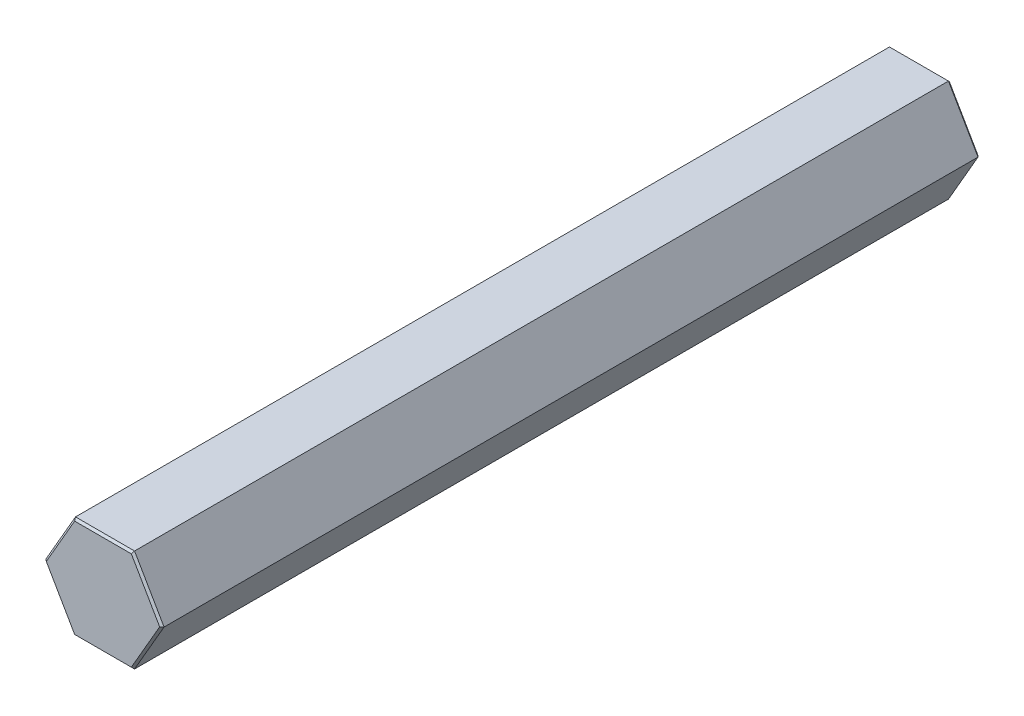
from build123d import *

# Parameters (mm, degrees)
BOSS_EXTRUDE1_DEPTH = 101.6
CHAMFER1_SIZE       = 0.254


with BuildPart() as part:
    # Sketch1 → Boss-Extrude1 (new body)
    with BuildSketch(Plane(origin=(0, 0, 0), x_dir=(-1, 0, 0), z_dir=(0, 0, -1))):
        Polygon((3.666174209, 6.35), (-3.666174209, 6.35), (-7.332348419, 0), (-3.666174209, -6.35), (3.666174209, -6.35), (7.332348419, 0), align=None)
    extrude(amount=-BOSS_EXTRUDE1_DEPTH)

    # Chamfer1
    chamfer1_edges = [part.edges().sort_by_distance(p)[0] for p in [
        (5.499261314, 3.175, 101.6),
        (5.499261314, -3.175, 101.6),
        (0, -6.35, 101.6),
        (-5.499261314, -3.175, 101.6),
        (-5.499261314, 3.175, 101.6),
        (-5.499261314, -3.175, 0),
        (0, -6.35, 0),
        (5.499261314, -3.175, 0),
        (5.499261314, 3.175, 0),
        (0, 6.35, 0),
        (-5.499261314, 3.175, 0),
        (0, 6.35, 101.6),
    ]]
    chamfer(chamfer1_edges, length=CHAMFER1_SIZE)


solid = part.part
